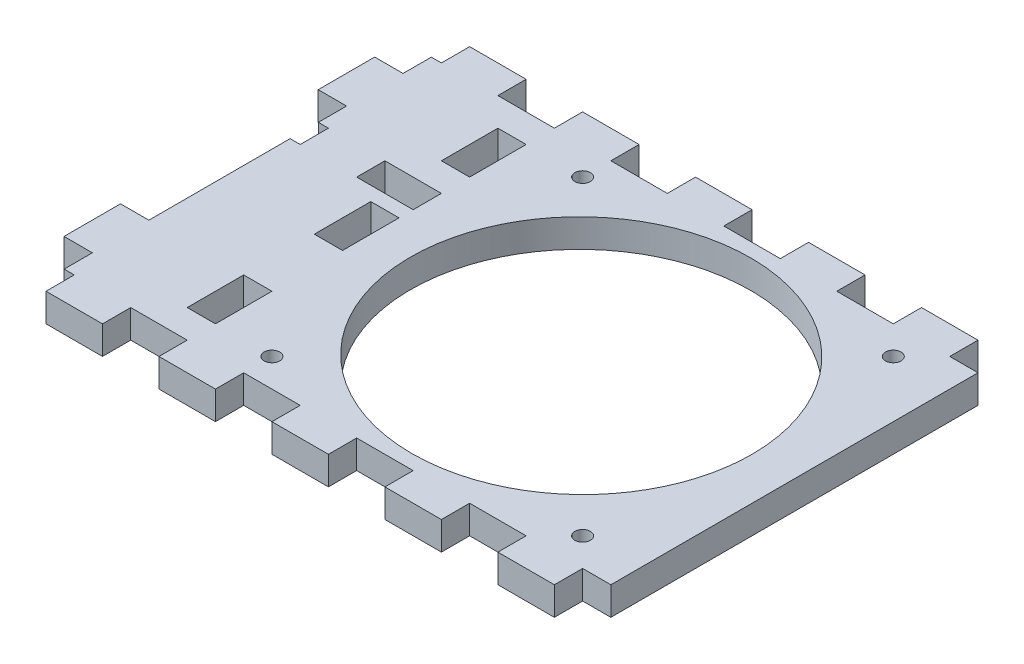
from build123d import *

# Parameters (mm, degrees)
SKETCH5_W           = 129.298204438
SKETCH5_H           = 6.35
BOSS_EXTRUDE1_DEPTH = 95.25
SKETCH6_R           = 1.75
SKETCH6_RX          = 38.405174548
SKETCH6_RY          = 38.1
CUT_EXTRUDE3_DEPTH  = 7.35
SKETCH7_W           = 12.7
SKETCH7_H           = 6.35
CUT_EXTRUDE4_DEPTH  = 7.3500001
LPATTERN1_COUNT     = 17
LPATTERN1_PITCH     = 25.4
SKETCH8_W           = 12.7
SKETCH8_H           = 6.35
CUT_EXTRUDE5_DEPTH  = 7.3500001
SKETCH9_W           = 6.35
SKETCH9_H           = 12.7
CUT_EXTRUDE6_DEPTH  = 7.3500001
SKETCH10_W          = 6.379369351
SKETCH10_H          = 6.35
SKETCH10_H_2        = 44.45
CUT_EXTRUDE7_DEPTH  = 7.3500001


with BuildPart() as part:
    # Sketch5 → Boss-Extrude1 (new body)
    with BuildSketch(Plane.XY):
        with Locations((94.609439566, 307.975)):
            Rectangle(SKETCH5_W, SKETCH5_H)
    extrude(amount=BOSS_EXTRUDE1_DEPTH)

    # Sketch6 → Cut-Extrude3 (cut, through all)
    with BuildSketch(Plane(origin=(0, 311.15, 0), x_dir=(1, 0, 0), z_dir=(0, 1, 0))):
        with Locations((76.708541785, -12.7)):
            Circle(SKETCH6_R)
        with Locations((76.708541785, -82.55)):
            Circle(SKETCH6_R)
        with Locations((146.558541785, -82.55)):
            Circle(SKETCH6_R)
        with Locations((146.558541785, -12.7)):
            Circle(SKETCH6_R)
        with Locations((111.328367236, -47.625)):
            Ellipse(SKETCH6_RX, SKETCH6_RY)
    extrude(amount=-CUT_EXTRUDE3_DEPTH, mode=Mode.SUBTRACT)

    # Sketch7 → Cut-Extrude4 (cut, through all)
    with BuildSketch(Plane(origin=(0, 311.15, 0), x_dir=(1, 0, 0), z_dir=(0, 1, 0))):
        with Locations((159.258541785, -3.175)):
            Rectangle(SKETCH7_W, SKETCH7_H)
        with Locations((159.258541785, -92.075)):
            Rectangle(SKETCH7_W, SKETCH7_H)
    cut_extrude4 = extrude(amount=-CUT_EXTRUDE4_DEPTH, mode=Mode.SUBTRACT)

    # LPattern1: Cut-Extrude4 ×17
    with Locations(*[(-i * LPATTERN1_PITCH, 0, 0) for i in range(1, LPATTERN1_COUNT)]):
        add(cut_extrude4, mode=Mode.SUBTRACT)

    # Sketch8 → Cut-Extrude5 (cut, through all)
    with BuildSketch(Plane(origin=(0, 311.15, 0), x_dir=(1, 0, 0), z_dir=(0, 1, 0))):
        with Locations((32.258541785, -34.925)):
            Rectangle(SKETCH8_W, SKETCH8_H)
        with Locations((57.658541785, -34.925)):
            Rectangle(SKETCH8_W, SKETCH8_H)
    extrude(amount=-CUT_EXTRUDE5_DEPTH, mode=Mode.SUBTRACT)

    # Sketch9 → Cut-Extrude6 (cut, through all)
    with BuildSketch(Plane(origin=(0, 311.15, 0), x_dir=(1, 0, 0), z_dir=(0, 1, 0))):
        with Locations((60.833541785, -47.625)):
            Rectangle(SKETCH9_W, SKETCH9_H)
        with Locations((60.833541785, -19.05)):
            Rectangle(SKETCH9_W, SKETCH9_H)
        with Locations((60.833541785, -76.2)):
            Rectangle(SKETCH9_W, SKETCH9_H)
    extrude(amount=-CUT_EXTRUDE6_DEPTH, mode=Mode.SUBTRACT)

    # Sketch10 → Cut-Extrude7 (cut, through all)
    with BuildSketch(Plane(origin=(0, 311.15, 0), x_dir=(1, 0, 0), z_dir=(0, 1, 0))):
        with Locations((33.150022023, -9.525)):
            Rectangle(SKETCH10_W, SKETCH10_H)
        with Locations((33.150022023, -47.625)):
            Rectangle(SKETCH10_W, SKETCH10_H_2)
        with Locations((33.150022023, -85.725)):
            Rectangle(SKETCH10_W, SKETCH10_H)
    extrude(amount=-CUT_EXTRUDE7_DEPTH, mode=Mode.SUBTRACT)


solid = part.part
